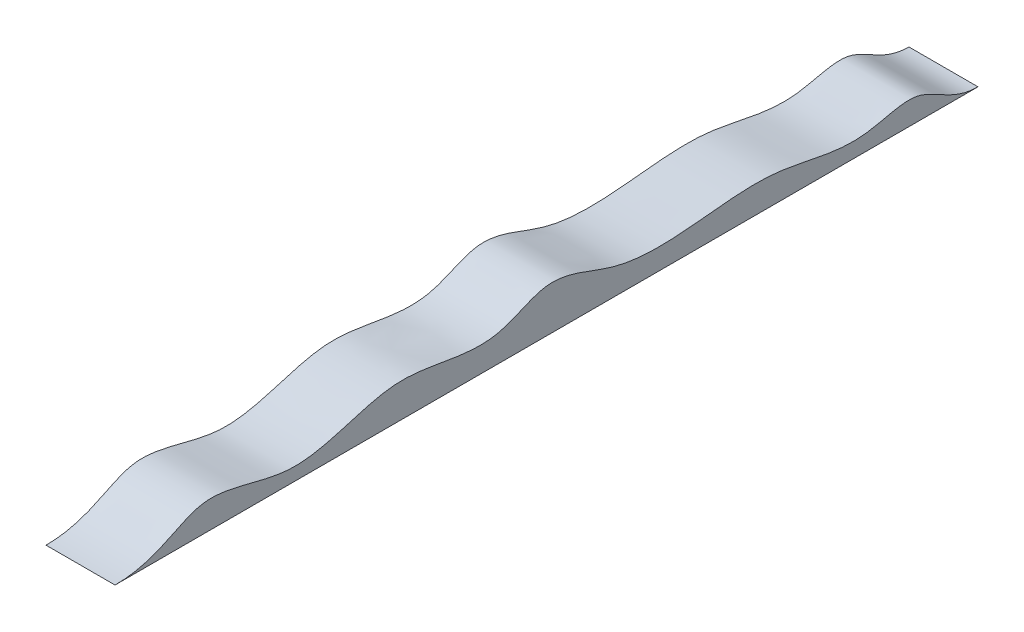
from build123d import *

# Parameters (mm, degrees)
EXTRUDE_1_DEPTH = 80


with BuildPart() as part:
    # 草图1 → 凸台-拉伸1 (new body, symmetric)
    with BuildSketch(Plane(origin=(0, 0, 0), x_dir=(0, 0, -1), z_dir=(1, 0, 0))):
        with BuildLine():
            Line((0, 0), (2000, 0))
            add(Edge.make_bspline(
                [(0, 0), (103.708782768, 0), (187.789239926, 107.255043871), (431.95087498, -12.171182924), (648.483362673, 121.078292906), (857.965641256, 26.116038228), (1013.5799623, 126.612269657), (1150.20260384, 48.698969974), (1329.443902917, 45.260209186), (1528.577518129, 82.045613008), (1707.183003809, 13.147277529), (1874.793577591, 78.631452899), (1936.768131832, 0), (2000, 0)],
                knots=[0, 0, 0, 0, 0.107406831, 0.205783949, 0.330571833, 0.447841411, 0.501425011, 0.577799743, 0.653570404, 0.765150421, 0.868832643, 0.924236581, 1, 1, 1, 1], degree=3))
        make_face()
    extrude(amount=EXTRUDE_1_DEPTH, both=True)


solid = part.part
